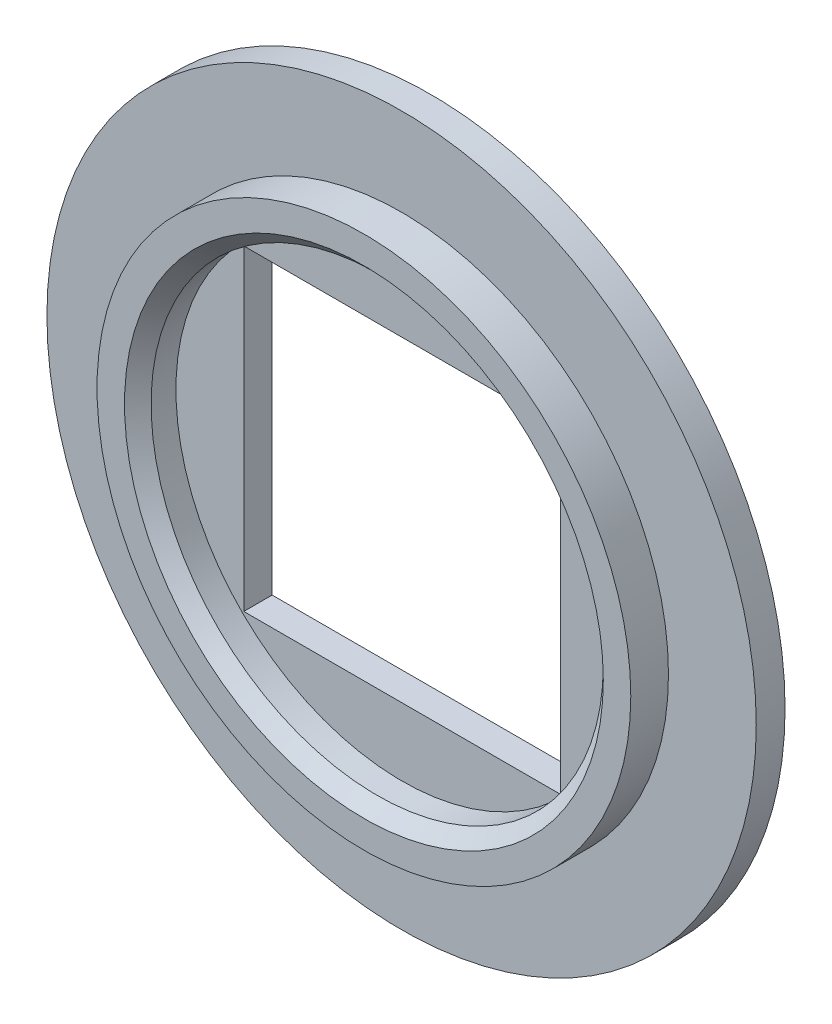
from build123d import *

# Parameters (mm, degrees)
SKETCH_1_R          = 8
EXTRUDE_1_DEPTH     = 0.65
EXTRUDE_START       = 0.65
SKETCH_2_R          = 6.02
SKETCH_2_R_2        = 5.1
EXTRUDE_2_DEPTH     = 0.85
CUT_EXTRUDE_START   = 0.65
SKETCH_3_R          = 5.1
CUT_EXTRUDE_1_DEPTH = 0.01
CUT_EXTRUDE_2_DEPTH = 0.64
CHAMFER_1_SIZE      = 0.3


with BuildPart() as part:
    # 草图1 → 凸台-拉伸1 (new body)
    with BuildSketch(Plane.XY):
        Circle(SKETCH_1_R)
    extrude(amount=EXTRUDE_1_DEPTH)

    # 草图2 → 凸台-拉伸2 (add)
    with BuildSketch(Plane.XY.offset(EXTRUDE_START)):
        Circle(SKETCH_2_R)
        Circle(SKETCH_2_R_2, mode=Mode.SUBTRACT)
    extrude(amount=EXTRUDE_2_DEPTH)

    # 草图3 → 切除-拉伸1 (cut)
    with BuildSketch(Plane.XY.offset(CUT_EXTRUDE_START)):
        Circle(SKETCH_3_R)
    extrude(amount=-CUT_EXTRUDE_1_DEPTH, mode=Mode.SUBTRACT)

    # 草图4 → 切除-拉伸2 (cut)
    with BuildSketch(Plane.XY):
        Polygon((-3.57, 3.57), (3.57, 3.57), (3.57, -3.57), (-3.57, -3.57), (-3.57, 0), align=None)
    extrude(amount=CUT_EXTRUDE_2_DEPTH, mode=Mode.SUBTRACT)

    # 倒角1
    chamfer_1_edges = [part.edges().sort_by_distance(p)[0] for p in [
        (-5.1, 0, 1.5),
    ]]
    chamfer(chamfer_1_edges, length=CHAMFER_1_SIZE)


solid = part.part
